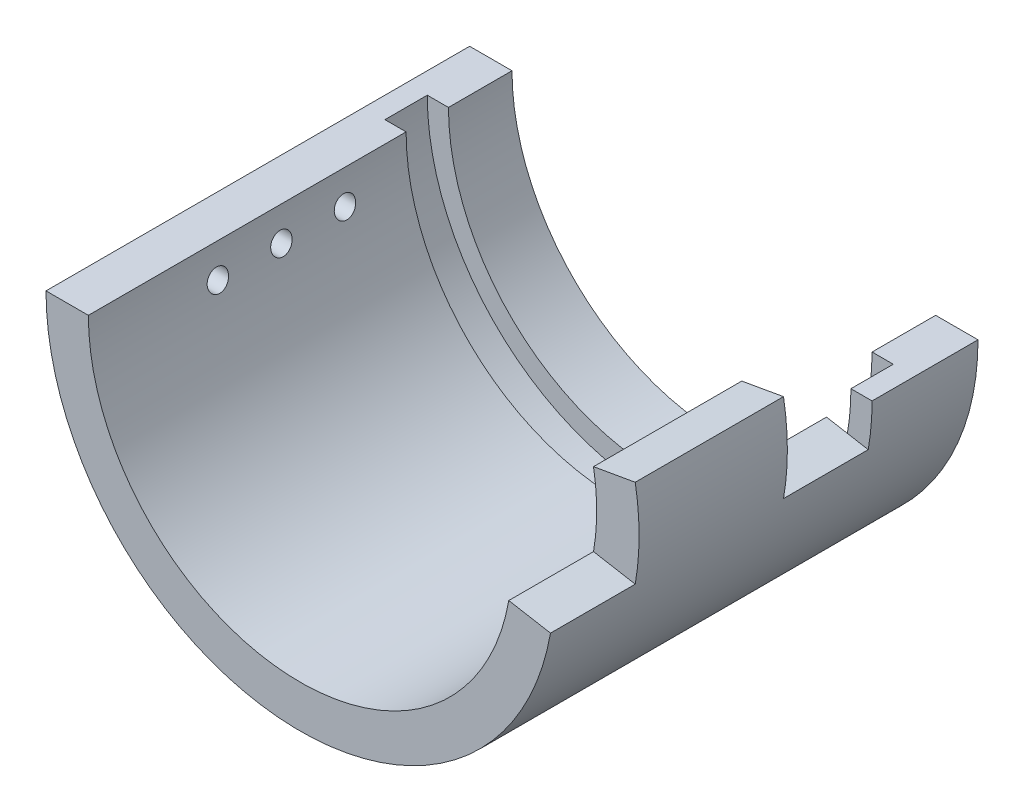
from build123d import *

# Parameters (mm, degrees)
REVOLVE1_ANGLE     = 180
SKETCH2_W          = 10
SKETCH2_H          = 35
REVOLVE2_ANGLE     = 10
SKETCH3_W          = 10
SKETCH3_H          = 20
CUT_REVOLVE1_ANGLE = 10
CUT_EXTRUDE2_REACH = 142
SKETCH5_R          = 2.5


with BuildPart() as part:
    # Sketch1 → Revolve1 (revolve)
    with BuildSketch(Plane(origin=(0, 0, 0), x_dir=(1, 0, 0), z_dir=(0, 1, 0))):
        Polygon((-60, 19.117647059), (-60, -80.882352941), (-50, -80.882352941), (-50, -5.882352941), (-55, -5.882352941), (-55, 4.117647059), (-50, 4.117647059), (-50, 19.117647059), align=None)
    revolve(axis=Axis((0, 0, -69.117647059), (0, 0, 1)), revolution_arc=REVOLVE1_ANGLE)

    # Sketch2 → Revolve2 (revolve)
    with BuildSketch(Plane(origin=(0, 0, 0), x_dir=(1, 0, 0), z_dir=(0, 1, 0))):
        with Locations((55, -43.382352941)):
            Rectangle(SKETCH2_W, SKETCH2_H)
    revolve(axis=Axis((0, 0, -76.274402341), (0, 0, 1)), revolution_arc=REVOLVE2_ANGLE)

    # Sketch3 → Cut-Revolve1 (revolve, cut)
    with BuildSketch(Plane(origin=(0, 0, 0), x_dir=(1, 0, 0), z_dir=(0, 1, 0))):
        with Locations((55, -70.882352941)):
            Rectangle(SKETCH3_W, SKETCH3_H)
        with Locations((55, -15.882352941)):
            Rectangle(SKETCH3_W, SKETCH3_H)
    revolve(axis=Axis((0, 0, -76.834720656), (0, 0, -1)), revolution_arc=CUT_REVOLVE1_ANGLE, mode=Mode.SUBTRACT)

    # Sketch5 → Cut-Extrude2 (cut, up to next)
    with BuildSketch(Plane(origin=(-80, 0, 0), x_dir=(0, 0, -1), z_dir=(1, 0, 0)), mode=Mode.PRIVATE) as cut_extrude2_sk1:
        with Locations((-35.882352941, -7.5)):
            Circle(SKETCH5_R)
    cut_extrude2_tool1 = extrude(cut_extrude2_sk1.sketch, amount=CUT_EXTRUDE2_REACH, mode=Mode.PRIVATE) & part.part
    add(cut_extrude2_tool1.solids().sort_by_distance((-80, -7.5, 35.882353))[0], mode=Mode.SUBTRACT)
    # Sketch5 → Cut-Extrude2 (cut, up to next)
    with BuildSketch(Plane(origin=(-80, 0, 0), x_dir=(0, 0, -1), z_dir=(1, 0, 0)), mode=Mode.PRIVATE) as cut_extrude2_sk2:
        with Locations((-50.882352941, -7.5)):
            Circle(SKETCH5_R)
    cut_extrude2_tool2 = extrude(cut_extrude2_sk2.sketch, amount=CUT_EXTRUDE2_REACH, mode=Mode.PRIVATE) & part.part
    add(cut_extrude2_tool2.solids().sort_by_distance((-80, -7.5, 50.882353))[0], mode=Mode.SUBTRACT)
    # Sketch5 → Cut-Extrude2 (cut, up to next)
    with BuildSketch(Plane(origin=(-80, 0, 0), x_dir=(0, 0, -1), z_dir=(1, 0, 0)), mode=Mode.PRIVATE) as cut_extrude2_sk3:
        with Locations((-20.882352941, -7.5)):
            Circle(SKETCH5_R)
    cut_extrude2_tool3 = extrude(cut_extrude2_sk3.sketch, amount=CUT_EXTRUDE2_REACH, mode=Mode.PRIVATE) & part.part
    add(cut_extrude2_tool3.solids().sort_by_distance((-80, -7.5, 20.882353))[0], mode=Mode.SUBTRACT)


solid = part.part
